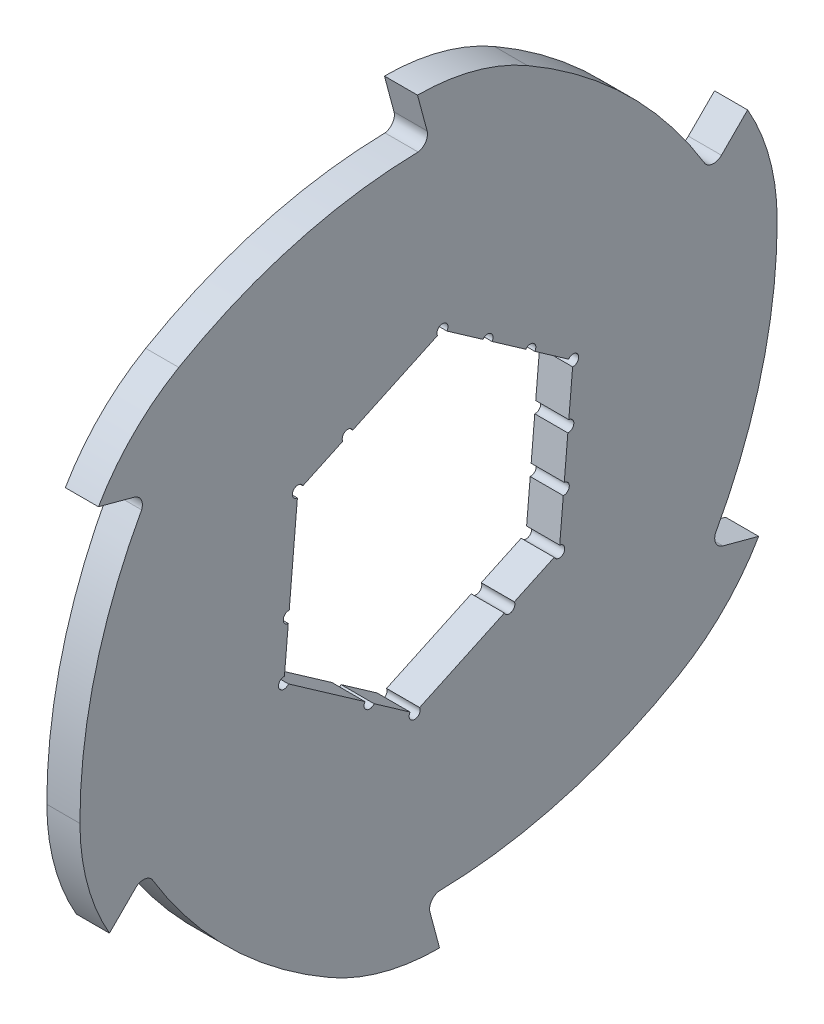
from build123d import *

# Parameters (mm, degrees)
SKETCH1_R                = 59
EXTRUDE1_DEPTH           = 3
EXTRUDE2_DEPTH           = 3
CIRPATTERN1_COUNT        = 6
F_2_0_2_DIAMETER_HOLE1_D = 2
F_2_0_2_DIAMETER_HOLE3_D = 2
F_2_0_2_DIAMETER_HOLE4_D = 2
CIRPATTERN2_COUNT        = 6
CIRPATTERN3_COUNT        = 2
CIRPATTERN3_ANGLE        = 60


with BuildPart() as part:
    # Sketch1 → Extrude1 (new, symmetric)
    with BuildSketch(Plane(origin=(0, 0, 0), x_dir=(0, 0, -1), z_dir=(1, 0, 0))):
        Circle(SKETCH1_R)
        Polygon((26.215177945, 12.224338236), (2.521001516, 28.815179183), (-23.694176429, 16.590840947), (-26.215177945, -12.224338236), (-2.521001516, -28.815179183), (23.694176429, -16.590840947), align=None, mode=Mode.SUBTRACT)
    extrude(amount=EXTRUDE1_DEPTH, both=True)

    # Sketch2 → Extrude2 (add, symmetric)
    with BuildSketch(Plane(origin=(0, 0, 0), x_dir=(0, 0, -1), z_dir=(1, 0, 0))):
        with BuildLine():
            Line((-2, 67.961805723), (-0.262709442, 61.478149092))
            ThreePointArc((-0.262709442, 61.478149092), (-0.58620663, 59.77173183), (-2.122608272, 58.961805723))
            ThreePointArc((-2.122608272, 58.961805723), (28.679663449, 51.560419941), (51.21368579, 29.294340542))
            ThreePointArc((51.21368579, 29.294340542), (36.791707484, 48.186627241), (17.927108603, 62.644803614))
            ThreePointArc((17.927108603, 62.644803614), (8.312130826, 66.609702921), (-2, 67.961805723))
        make_face()
    extrude2 = extrude(amount=EXTRUDE2_DEPTH, both=True)

    # CirPattern1: Extrude2 ×6 about axis
    cirpattern1_axis = Axis((0, 0, 0), (1, 0, 0))
    for i in range(1, CIRPATTERN1_COUNT):
        add(extrude2.rotate(cirpattern1_axis, i * 360 / CIRPATTERN1_COUNT))

    # 2.0 _2_ Diameter Hole1 (through all)
    with Locations(Plane(origin=(3, 0, 0), x_dir=(0, 0, -1), z_dir=(1, 0, 0))):
        with Locations((2.521001516, 28.815179183), (26.215177945, 12.224338236), (23.694176429, -16.590840947), (-2.521001516, -28.815179183), (-26.215177945, -12.224338236), (-23.694176429, 16.590840947)):
            Hole(F_2_0_2_DIAMETER_HOLE1_D / 2)

    # 2.0 _2_ Diameter Hole3 (through all)
    with Locations(Plane(origin=(3, 0, 0), x_dir=(0, 0, -1), z_dir=(1, 0, 0))):
        with Locations((10.692111007, 23.093706722)):
            f_2_0_2_diameter_hole3 = Hole(F_2_0_2_DIAMETER_HOLE3_D / 2)

    # 2.0 _2_ Diameter Hole4 (through all)
    with Locations(Plane(origin=(3, 0, 0), x_dir=(0, 0, -1), z_dir=(1, 0, 0))):
        with Locations((18.453644476, 17.659022479)):
            f_2_0_2_diameter_hole4 = Hole(F_2_0_2_DIAMETER_HOLE4_D / 2)

    # CirPattern2: 2.0 _2_ Diameter Hole3 ×6 about axis
    cirpattern2_axis = Axis((0, 0, 0), (1, 0, 0))
    for i in range(1, CIRPATTERN2_COUNT):
        add(f_2_0_2_diameter_hole3.rotate(cirpattern2_axis, i * 360 / CIRPATTERN2_COUNT), mode=Mode.SUBTRACT)

    # CirPattern3: 2.0 _2_ Diameter Hole4 ×2 about axis
    cirpattern3_axis = Axis((-5.5, 0, 0), (-1, 0, 0))
    for i in range(1, CIRPATTERN3_COUNT):
        add(f_2_0_2_diameter_hole4.rotate(cirpattern3_axis, i * CIRPATTERN3_ANGLE / (CIRPATTERN3_COUNT - 1)), mode=Mode.SUBTRACT)


solid = part.part
